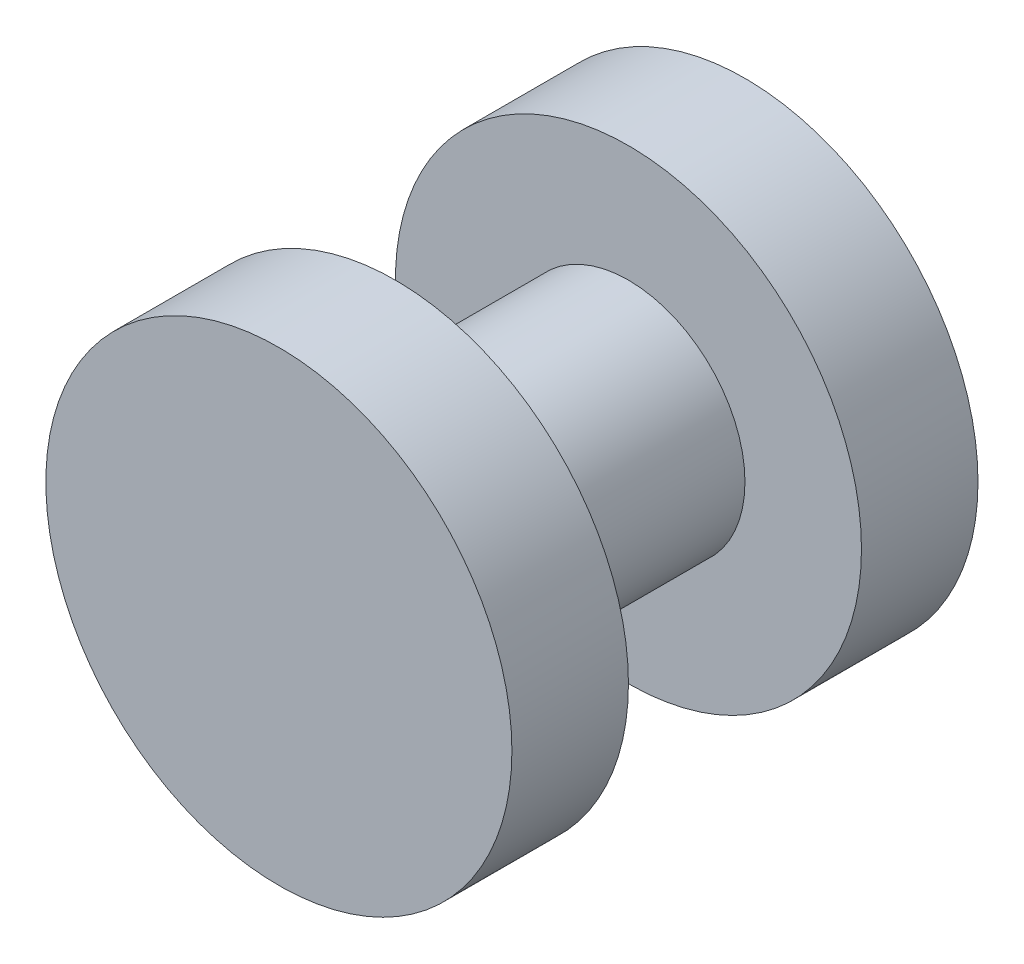
from build123d import *

# Parameters (mm, degrees)
SKETCH1_R           = 6.35
BOSS_EXTRUDE2_DEPTH = 3.175
SKETCH2_R           = 3.175
BOSS_EXTRUDE3_DEPTH = 6.35
SKETCH3_R           = 6.35
BOSS_EXTRUDE4_DEPTH = 3.175


with BuildPart() as part:
    # Sketch1 → Boss-Extrude2 (new body)
    with BuildSketch(Plane.XY):
        Circle(SKETCH1_R)
    extrude(amount=BOSS_EXTRUDE2_DEPTH)

    # Sketch2 → Boss-Extrude3 (add)
    with BuildSketch(Plane.XY.offset(3.175)):
        Circle(SKETCH2_R)
    extrude(amount=BOSS_EXTRUDE3_DEPTH)

    # Sketch3 → Boss-Extrude4 (add)
    with BuildSketch(Plane.XY.offset(9.525)):
        Circle(SKETCH3_R)
    extrude(amount=BOSS_EXTRUDE4_DEPTH)


solid = part.part
